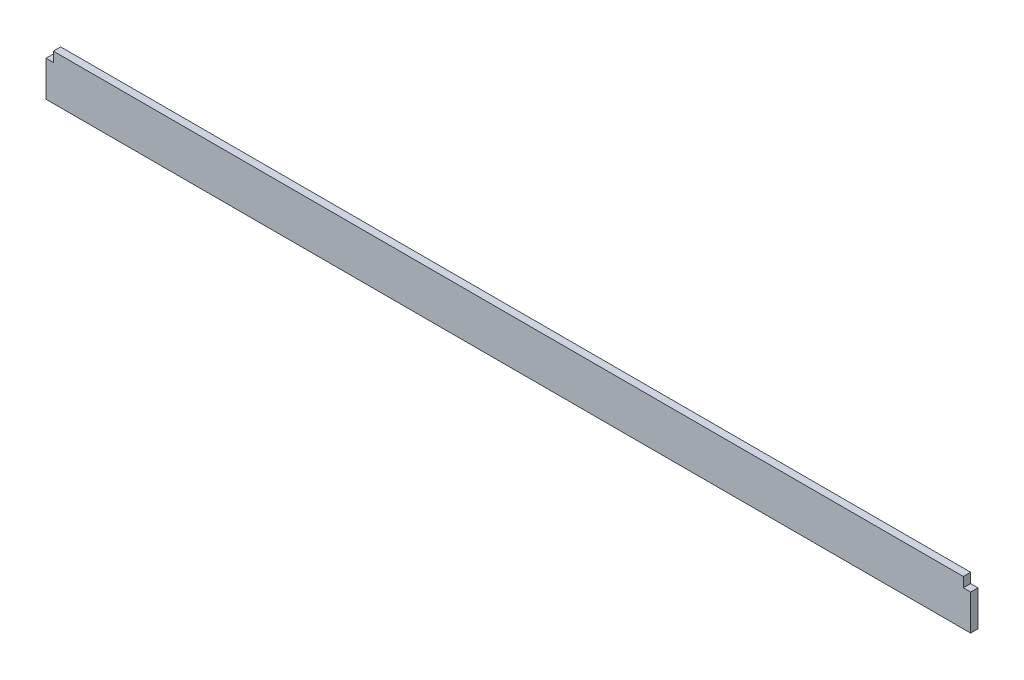
from build123d import *

# Parameters (mm, degrees)
BOSS_EXTRUDE1_DEPTH = 38.1


with BuildPart() as part:
    # Sketch1 → Boss-Extrude1 (new body)
    with BuildSketch(Plane.XY):
        Polygon((0, 0), (4787.9, 0), (4787.9, 184.15), (4749.8, 184.15), (4749.8, 234.95), (38.1, 234.95), (38.1, 184.15), (0, 184.15), align=None)
    extrude(amount=BOSS_EXTRUDE1_DEPTH)


solid = part.part
